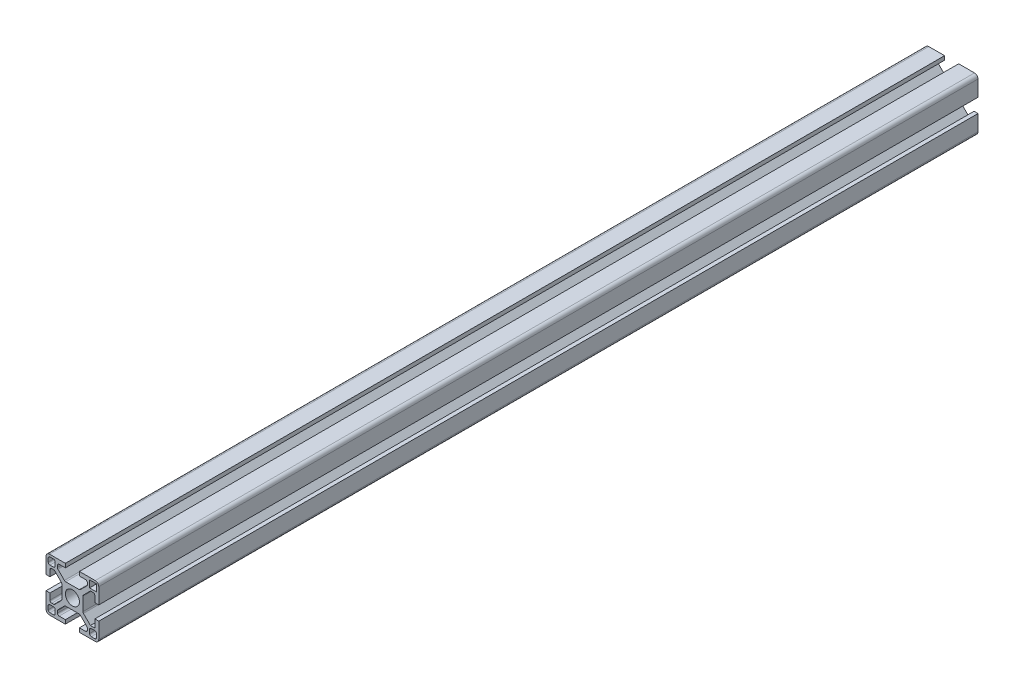
from build123d import *

# Parameters (mm, degrees)
SKETCH1_R           = 4
SKETCH1_W           = 4
SKETCH1_H           = 4
BOSS_EXTRUDE1_DEPTH = 500


with BuildPart() as part:
    # Sketch1 → Boss-Extrude1 (new body)
    with BuildSketch(Plane.XY):
        with BuildLine():
            Line((-15, -4), (-15, -13))
            ThreePointArc((-15, -13), (-14.414213562, -14.414213562), (-13, -15))
            Line((-13, -15), (-4, -15))
            Line((-4, -15), (-4, -12.75))
            Line((-4, -12.75), (-7.5, -12.75))
            ThreePointArc((-7.5, -12.75), (-8.207106781, -12.457106781), (-8.5, -11.75))
            Line((-8.5, -11.75), (-8.5, -10.681980515))
            ThreePointArc((-8.5, -10.681980515), (-8.423879533, -10.299297083), (-8.207106781, -9.974873734))
            Line((-8.207106781, -9.974873734), (-4.525126266, -6.292893219))
            ThreePointArc((-4.525126266, -6.292893219), (-4.200702917, -6.076120467), (-3.818019485, -6))
            Line((-3.818019485, -6), (3.818019485, -6))
            ThreePointArc((3.818019485, -6), (4.200702917, -6.076120467), (4.525126266, -6.292893219))
            Line((4.525126266, -6.292893219), (8.207106781, -9.974873734))
            ThreePointArc((8.207106781, -9.974873734), (8.423879533, -10.299297083), (8.5, -10.681980515))
            Line((8.5, -10.681980515), (8.5, -11.75))
            ThreePointArc((8.5, -11.75), (8.207106781, -12.457106781), (7.5, -12.75))
            Line((7.5, -12.75), (4, -12.75))
            Line((4, -12.75), (4, -15))
            Line((4, -15), (13, -15))
            ThreePointArc((13, -15), (14.414213562, -14.414213562), (15, -13))
            Line((15, -13), (15, -4))
            Line((15, -4), (12.75, -4))
            Line((12.75, -4), (12.75, -8.5))
            Line((12.75, -8.5), (10.267766953, -8.5))
            Line((10.267766953, -8.5), (6.292893219, -4.525126266))
            ThreePointArc((6.292893219, -4.525126266), (6.076120467, -4.200702917), (6, -3.818019485))
            Line((6, -3.818019485), (6, 3.818019485))
            ThreePointArc((6, 3.818019485), (6.076120467, 4.200702917), (6.292893219, 4.525126266))
            Line((6.292893219, 4.525126266), (9.974873734, 8.207106781))
            ThreePointArc((9.974873734, 8.207106781), (10.299297083, 8.423879533), (10.681980515, 8.5))
            Line((10.681980515, 8.5), (11.75, 8.5))
            ThreePointArc((11.75, 8.5), (12.457106781, 8.207106781), (12.75, 7.5))
            Line((12.75, 7.5), (12.75, 4))
            Line((12.75, 4), (15, 4))
            Line((15, 4), (15, 13))
            ThreePointArc((15, 13), (14.414213562, 14.414213562), (13, 15))
            Line((13, 15), (4, 15))
            Line((4, 15), (4, 12.75))
            Line((4, 12.75), (7.5, 12.75))
            ThreePointArc((7.5, 12.75), (8.207106781, 12.457106781), (8.5, 11.75))
            Line((8.5, 11.75), (8.5, 10.681980515))
            ThreePointArc((8.5, 10.681980515), (8.423879533, 10.299297083), (8.207106781, 9.974873734))
            Line((8.207106781, 9.974873734), (4.525126266, 6.292893219))
            ThreePointArc((4.525126266, 6.292893219), (4.200702917, 6.076120467), (3.818019485, 6))
            Line((3.818019485, 6), (-3.818019485, 6))
            ThreePointArc((-3.818019485, 6), (-4.200702917, 6.076120467), (-4.525126266, 6.292893219))
            Line((-4.525126266, 6.292893219), (-8.207106781, 9.974873734))
            ThreePointArc((-8.207106781, 9.974873734), (-8.423879533, 10.299297083), (-8.5, 10.681980515))
            Line((-8.5, 10.681980515), (-8.5, 11.75))
            ThreePointArc((-8.5, 11.75), (-8.207106781, 12.457106781), (-7.5, 12.75))
            Line((-7.5, 12.75), (-4, 12.75))
            Line((-4, 12.75), (-4, 15))
            Line((-4, 15), (-13, 15))
            ThreePointArc((-13, 15), (-14.414213562, 14.414213562), (-15, 13))
            Line((-15, 13), (-15, 4))
            Line((-15, 4), (-12.75, 4))
            Line((-12.75, 4), (-12.75, 7.5))
            ThreePointArc((-12.75, 7.5), (-12.457106781, 8.207106781), (-11.75, 8.5))
            Line((-11.75, 8.5), (-10.681980515, 8.5))
            ThreePointArc((-10.681980515, 8.5), (-10.299297083, 8.423879533), (-9.974873734, 8.207106781))
            Line((-9.974873734, 8.207106781), (-6.292893219, 4.525126266))
            ThreePointArc((-6.292893219, 4.525126266), (-6.076120467, 4.200702917), (-6, 3.818019485))
            Line((-6, 3.818019485), (-6, -3.818019485))
            ThreePointArc((-6, -3.818019485), (-6.076120467, -4.200702917), (-6.292893219, -4.525126266))
            Line((-6.292893219, -4.525126266), (-9.974873734, -8.207106781))
            ThreePointArc((-9.974873734, -8.207106781), (-10.299297083, -8.423879533), (-10.681980515, -8.5))
            Line((-10.681980515, -8.5), (-11.75, -8.5))
            ThreePointArc((-11.75, -8.5), (-12.457106781, -8.207106781), (-12.75, -7.5))
            Line((-12.75, -7.5), (-12.75, -4))
            Line((-12.75, -4), (-15, -4))
        make_face()
        Circle(SKETCH1_R, mode=Mode.SUBTRACT)
        with BuildLine():
            Line((9.75, -10.75), (9.75, -12.75))
            ThreePointArc((9.75, -12.75), (10.042893219, -13.457106781), (10.75, -13.75))
            Line((10.75, -13.75), (12.75, -13.75))
            ThreePointArc((12.75, -13.75), (13.457106781, -13.457106781), (13.75, -12.75))
            Line((13.75, -12.75), (13.75, -10.75))
            ThreePointArc((13.75, -10.75), (13.457106781, -10.042893219), (12.75, -9.75))
            Line((12.75, -9.75), (10.75, -9.75))
            ThreePointArc((10.75, -9.75), (10.042893219, -10.042893219), (9.75, -10.75))
        make_face(mode=Mode.SUBTRACT)
        with Locations((11.75, 11.75)):
            Rectangle(SKETCH1_W, SKETCH1_H, mode=Mode.SUBTRACT)
        with BuildLine():
            Line((-10.75, 13.75), (-12.75, 13.75))
            ThreePointArc((-12.75, 13.75), (-13.457106781, 13.457106781), (-13.75, 12.75))
            Line((-13.75, 12.75), (-13.75, 10.75))
            ThreePointArc((-13.75, 10.75), (-13.457106781, 10.042893219), (-12.75, 9.75))
            Line((-12.75, 9.75), (-10.75, 9.75))
            ThreePointArc((-10.75, 9.75), (-10.042893219, 10.042893219), (-9.75, 10.75))
            Line((-9.75, 10.75), (-9.75, 12.75))
            ThreePointArc((-9.75, 12.75), (-10.042893219, 13.457106781), (-10.75, 13.75))
        make_face(mode=Mode.SUBTRACT)
        with BuildLine():
            Line((-12.75, -13.75), (-10.75, -13.75))
            ThreePointArc((-10.75, -13.75), (-10.042893219, -13.457106781), (-9.75, -12.75))
            Line((-9.75, -12.75), (-9.75, -10.75))
            ThreePointArc((-9.75, -10.75), (-10.042893219, -10.042893219), (-10.75, -9.75))
            Line((-10.75, -9.75), (-12.75, -9.75))
            ThreePointArc((-12.75, -9.75), (-13.457106781, -10.042893219), (-13.75, -10.75))
            Line((-13.75, -10.75), (-13.75, -12.75))
            ThreePointArc((-13.75, -12.75), (-13.457106781, -13.457106781), (-12.75, -13.75))
        make_face(mode=Mode.SUBTRACT)
    extrude(amount=BOSS_EXTRUDE1_DEPTH)


solid = part.part
